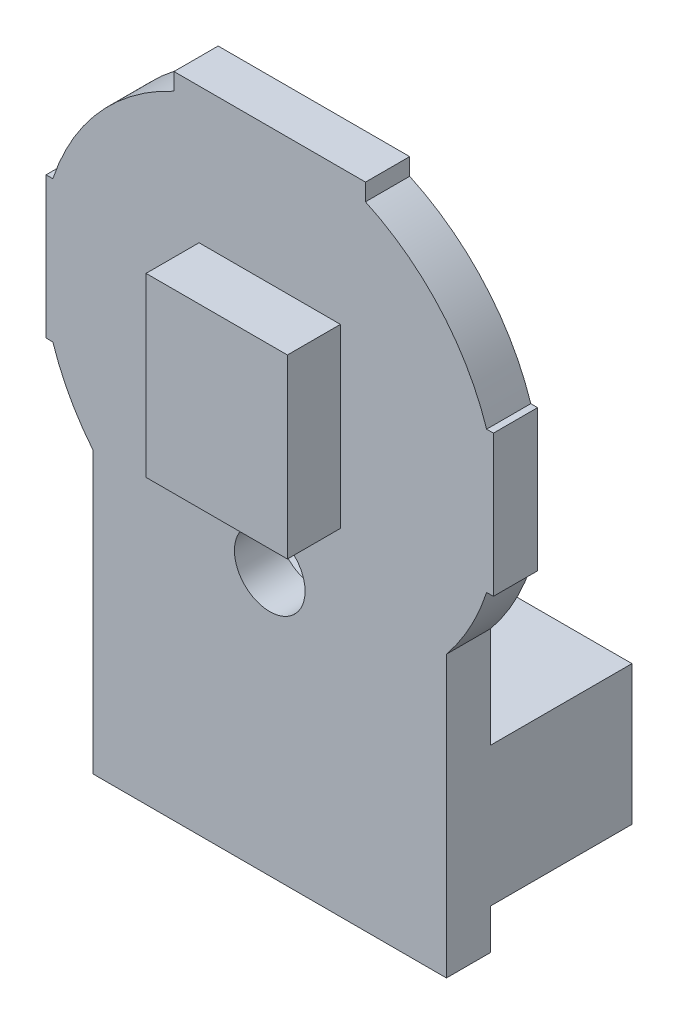
from build123d import *

# Parameters (mm, degrees)
SKETCH1_R              = 1.27
BOSS_EXTRUDE1_DEPTH    = 1.5875
SKETCH2_W              = 12.7
SKETCH2_H              = 5.0038
SKETCH2_W_2            = 11.176
SKETCH2_H_2            = 3.4798
BOSS_EXTRUDE2_DEPTH    = 5.08
SKETCH4_W              = 5.08
SKETCH4_H              = 6.35
BOSS_EXTRUDE3_DEPTH    = 1.905
SKETCH5_W              = 11.176
SKETCH5_H              = 3.4798
BOSS_EXTRUDE4_DEPTH    = 0.508
SKETCH6_W              = 0.381
SKETCH6_H              = 0.381
BOSS_EXTRUDE5_DEPTH    = 4.064
LPATTERN1_COUNT        = 5
LPATTERN1_PITCH        = 1.5875
SKETCH7_W              = 3.048
SKETCH7_H              = 1.524
BOSS_EXTRUDE6_DEPTH    = 0.8636
SKETCH7_3_W            = 1.524
SKETCH7_3_H            = 0.762
BOSS_EXTRUDE7_DEPTH    = 0.508
SKETCH7_3_W_2          = 1.778
BOSS_EXTRUDE7_2_DEPTH  = 0.508
SKETCH7_4_W            = 0.635
SKETCH7_4_H            = 0.9652
BOSS_EXTRUDE8_DEPTH    = 0.381
BOSS_EXTRUDE8_2_DEPTH  = 0.381
SKETCH7_5_W            = 1.016
SKETCH7_5_H            = 1.778
BOSS_EXTRUDE9_DEPTH    = 1.27
SKETCH7_6_W            = 1.778
SKETCH7_6_H            = 1.016
BOSS_EXTRUDE10_DEPTH   = 0.381
SKETCH7_6_W_2          = 1.016
SKETCH7_6_H_2          = 1.778
BOSS_EXTRUDE10_2_DEPTH = 0.381
SKETCH10_W             = 2.413
SKETCH10_H             = 0.762
CUT_EXTRUDE2_DEPTH     = 2.54


with BuildPart() as part:
    # Sketch1 → Boss-Extrude1 (new body)
    with BuildSketch(Plane.XY):
        with BuildLine():
            Line((-6.35, -9.497254818), (6.35, -9.497254818))
            Line((6.35, -9.497254818), (6.35, 0.580990975))
            ThreePointArc((6.35, 0.580990975), (7.194788478, 1.836453568), (7.794430359, 3.2258))
            Line((7.794430359, 3.2258), (8.0391, 3.2258))
            Line((8.0391, 3.2258), (8.0391, 8.3058))
            Line((8.0391, 8.3058), (7.794430359, 8.3058))
            ThreePointArc((7.794430359, 8.3058), (6.129120563, 11.209936823), (3.4417, 13.206192848))
            Line((3.4417, 13.206192848), (3.4417, 13.819945182))
            Line((3.4417, 13.819945182), (-3.4417, 13.819945182))
            Line((-3.4417, 13.819945182), (-3.4417, 13.206192848))
            ThreePointArc((-3.4417, 13.206192848), (-6.129120563, 11.209936823), (-7.794430359, 8.3058))
            Line((-7.794430359, 8.3058), (-8.0391, 8.3058))
            Line((-8.0391, 8.3058), (-8.0391, 3.2258))
            Line((-8.0391, 3.2258), (-7.794430359, 3.2258))
            ThreePointArc((-7.794430359, 3.2258), (-7.194788478, 1.836453568), (-6.35, 0.580990975))
            Line((-6.35, 0.580990975), (-6.35, -9.497254818))
        make_face()
        Circle(SKETCH1_R, mode=Mode.SUBTRACT)
    extrude(amount=BOSS_EXTRUDE1_DEPTH)


with BuildPart() as body_2:
    # Sketch2 → Boss-Extrude2 (new body)
    with BuildSketch(Plane(origin=(0, 0, 0), x_dir=(-1, 0, 0), z_dir=(0, 0, -1))):
        with Locations((0, -5.547554818)):
            Rectangle(SKETCH2_W, SKETCH2_H)
        with Locations((0, -5.547554818)):
            Rectangle(SKETCH2_W_2, SKETCH2_H_2, mode=Mode.SUBTRACT)
    extrude(amount=BOSS_EXTRUDE2_DEPTH)

    # Sketch10 → Cut-Extrude2 (cut)
    with BuildSketch(Plane(origin=(0, 0, -5.08), x_dir=(-1, 0, 0), z_dir=(0, 0, -1))):
        with Locations((0, -3.426654818)):
            Rectangle(SKETCH10_W, SKETCH10_H)
    extrude(amount=-CUT_EXTRUDE2_DEPTH, mode=Mode.SUBTRACT)


with BuildPart() as body_3:
    # Sketch4 → Boss-Extrude3 (new body)
    with BuildSketch(Plane.XY.offset(1.5875)):
        with Locations((0, 5.7658)):
            Rectangle(SKETCH4_W, SKETCH4_H)
    extrude(amount=BOSS_EXTRUDE3_DEPTH)


with BuildPart() as body_4:
    # Sketch5 → Boss-Extrude4 (new body)
    with BuildSketch(Plane(origin=(0, 0, 0), x_dir=(-1, 0, 0), z_dir=(0, 0, -1))):
        with Locations((0, -5.547554818)):
            Rectangle(SKETCH5_W, SKETCH5_H)
    extrude(amount=BOSS_EXTRUDE4_DEPTH)

    # Sketch6 → Boss-Extrude5 (add)
    with BuildSketch(Plane(origin=(0, 0, -0.508), x_dir=(-1, 0, 0), z_dir=(0, 0, -1))):
        with Locations((3.175, -4.912554818)):
            Rectangle(SKETCH6_W, SKETCH6_H)
        with Locations((3.175, -6.182554818)):
            Rectangle(SKETCH6_W, SKETCH6_H)
    boss_extrude5 = extrude(amount=BOSS_EXTRUDE5_DEPTH)

    # LPattern1: Boss-Extrude5 ×5
    with Locations(*[(i * LPATTERN1_PITCH, 0, 0) for i in range(1, LPATTERN1_COUNT)]):
        add(boss_extrude5)


with BuildPart() as body_5:
    # Sketch7 → Boss-Extrude6 (new body)
    with BuildSketch(Plane(origin=(0, 0, 0), x_dir=(-1, 0, 0), z_dir=(0, 0, -1))):
        with Locations((4.618593555, 3.105353297)):
            Rectangle(SKETCH7_W, SKETCH7_H)
    extrude(amount=BOSS_EXTRUDE6_DEPTH)


with BuildPart() as body_6:
    # Sketch7_3 → Boss-Extrude7 (new body)
    with BuildSketch(Plane(origin=(0, 0, 0), x_dir=(-1, 0, 0), z_dir=(0, 0, -1))):
        with Locations((0, 12.1412)):
            Rectangle(SKETCH7_3_W, SKETCH7_3_H)
    extrude(amount=BOSS_EXTRUDE7_DEPTH)


with BuildPart() as body_7:
    # Sketch7_3 → Boss-Extrude7 2 (new body)
    with BuildSketch(Plane(origin=(0, 0, 0), x_dir=(-1, 0, 0), z_dir=(0, 0, -1))):
        with Locations((4.445, -0.378654818)):
            Rectangle(SKETCH7_3_W_2, SKETCH7_3_H)
    extrude(amount=BOSS_EXTRUDE7_2_DEPTH)


with BuildPart() as body_8:
    # Sketch7_4 → Boss-Extrude8 (new body)
    with BuildSketch(Plane(origin=(0, 0, 0), x_dir=(-1, 0, 0), z_dir=(0, 0, -1))):
        with Locations((-4.700690056, 0.130459395)):
            Rectangle(SKETCH7_4_W, SKETCH7_4_H)
    extrude(amount=BOSS_EXTRUDE8_DEPTH)


with BuildPart() as body_9:
    # Sketch7_4 → Boss-Extrude8 2 (new body)
    with BuildSketch(Plane(origin=(0, 0, 0), x_dir=(-1, 0, 0), z_dir=(0, 0, -1))):
        with Locations((-3.430690056, 0.130459395)):
            Rectangle(SKETCH7_4_W, SKETCH7_4_H)
    extrude(amount=BOSS_EXTRUDE8_2_DEPTH)


with BuildPart() as body_10:
    # Sketch7_5 → Boss-Extrude9 (new body)
    with BuildSketch(Plane(origin=(0, 0, 0), x_dir=(-1, 0, 0), z_dir=(0, 0, -1))):
        with Locations((4.4831, 6.199945182)):
            Rectangle(SKETCH7_5_W, SKETCH7_5_H)
    extrude(amount=BOSS_EXTRUDE9_DEPTH)


with BuildPart() as body_11:
    # Sketch7_6 → Boss-Extrude10 (new body)
    with BuildSketch(Plane(origin=(0, 0, 0), x_dir=(-1, 0, 0), z_dir=(0, 0, -1))):
        with Locations((0.635, 10.7442)):
            Rectangle(SKETCH7_6_W, SKETCH7_6_H)
    extrude(amount=BOSS_EXTRUDE10_DEPTH)


with BuildPart() as body_12:
    # Sketch7_6 → Boss-Extrude10 2 (new body)
    with BuildSketch(Plane(origin=(0, 0, 0), x_dir=(-1, 0, 0), z_dir=(0, 0, -1))):
        with Locations((-4.4831, 7.215945182)):
            Rectangle(SKETCH7_6_W_2, SKETCH7_6_H_2)
    extrude(amount=BOSS_EXTRUDE10_2_DEPTH)


with BuildPart() as part_1:
    add(part.part)

    # Combine2: union body 2, body 11, body 12, body 10, body 9, body 6, body 7, body 5, body 4, body 3, body 8
    add(body_2.part)
    add(body_11.part)
    add(body_12.part)
    add(body_10.part)
    add(body_9.part)
    add(body_6.part)
    add(body_7.part)
    add(body_5.part)
    add(body_4.part)
    add(body_3.part)
    add(body_8.part)


solid = part_1.part
